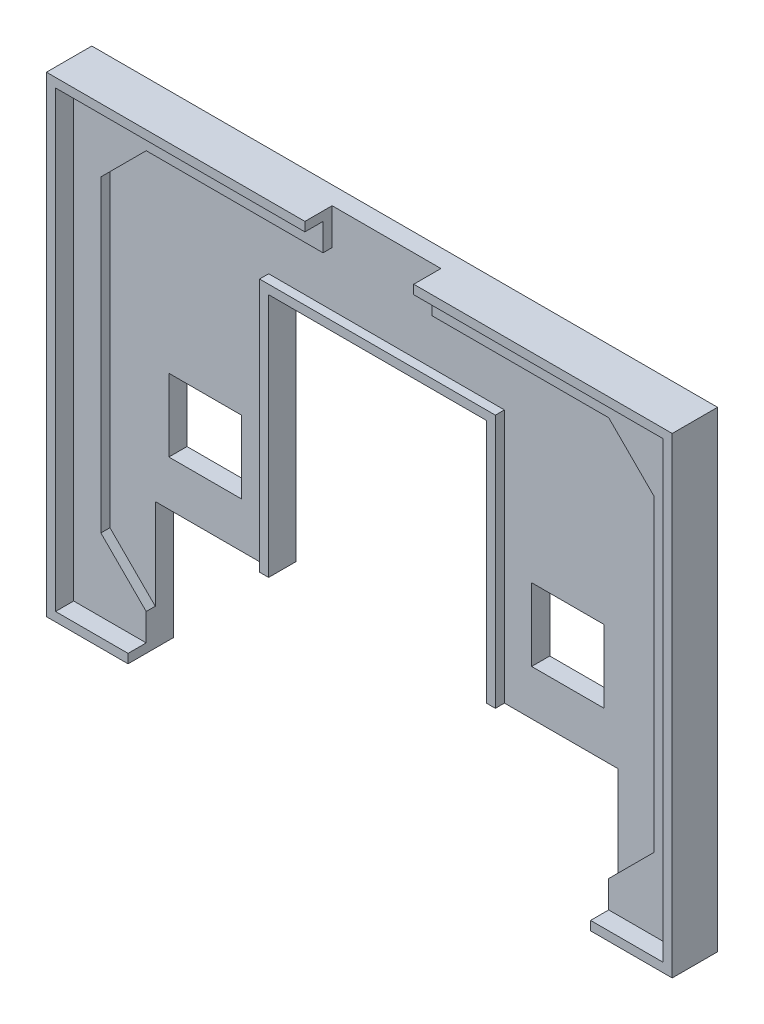
from build123d import *

# Parameters (mm, degrees)
SKICA1_W                    = 67
SKICA1_H                    = 50
P_IDAT_VYSUNUT_M1_DEPTH     = 3
ODEBRAT_VYSUNUT_M1_DEPTH    = 1
SKICA3_W                    = 8
SKICA3_H                    = 8
ODEBRAT_VYSUNUT_M2_DEPTH    = 4
VYSUNOUT_TENKOST_NN_1_DEPTH = 1
VYSUNOUT_TENKOST_NN_2_DEPTH = 5
SKICA6_W                    = 12
SKICA6_H                    = 4
ODEBRAT_VYSUNUT_M3_DEPTH    = 4
ODEBRAT_VYSUNUT_M5_DEPTH    = 1
P_IDAT_START                = -1
P_IDAT_VYSUNUT_M5_DEPTH     = 1
P_IDAT_VYSUNUT_M6_DEPTH     = 1
ODEBRAT_VYSUNUT_M6_DEPTH    = 1
SKICA13_W                   = 1.825387876
SKICA13_H                   = 1.792199005
P_IDAT_VYSUNUT_M7_DEPTH     = 1


with BuildPart() as part:
    # Skica1 → Přidat vysunutím1 (new body)
    with BuildSketch(Plane.XY):
        Rectangle(SKICA1_W, SKICA1_H)
    extrude(amount=P_IDAT_VYSUNUT_M1_DEPTH)

    # Skica2 → Odebrat vysunutím1 (cut)
    with BuildSketch(Plane.XY.offset(3)):
        Polygon((-25.5, -22), (-30.5, -17), (-30.5, 17), (-25.5, 22), (25.5, 22), (30.5, 17), (30.5, -17), (25.5, -22), align=None)
    extrude(amount=-ODEBRAT_VYSUNUT_M1_DEPTH, mode=Mode.SUBTRACT)

    # Skica3 → Odebrat vysunutím2 (cut, through all)
    with BuildSketch(Plane(origin=(0, 0, 0), x_dir=(-1, 0, 0), z_dir=(0, 0, -1))):
        with Locations((20, -3)):
            Rectangle(SKICA3_W, SKICA3_H)
        with Locations((-20, -3)):
            Rectangle(SKICA3_W, SKICA3_H)
        Polygon((25.5, -25), (-25.5, -25), (-25.5, -12), (-12, -12), (-12, 15), (12, 15), (12, -12), (25.5, -12), align=None)
    extrude(amount=-ODEBRAT_VYSUNUT_M2_DEPTH, mode=Mode.SUBTRACT)

    # Skica4 → Vysunout tenkostěnný1 (add)
    with BuildSketch(Plane.XY.offset(2)):
        Polygon((-12, -12), (-12, 15), (12, 15), (12, -12), (13, -12), (13, 16), (-13, 16), (-13, -12), align=None)
    extrude(amount=VYSUNOUT_TENKOST_NN_1_DEPTH)

    # Skica5 → Vysunout tenkostěnný2 (add)
    with BuildSketch(Plane(origin=(0, 0, 0), x_dir=(-1, 0, 0), z_dir=(0, 0, -1))):
        Polygon((-25.5, -25), (-33.5, -25), (-33.5, 25), (33.5, 25), (33.5, -25), (25.5, -25), (25.5, -26), (34.5, -26), (34.5, 26), (-34.5, 26), (-34.5, -26), (-25.5, -26), align=None)
    extrude(amount=-VYSUNOUT_TENKOST_NN_2_DEPTH)

    # Skica6 → Odebrat vysunutím3 (cut, through all)
    with BuildSketch(Plane.XY.offset(2)):
        with Locations((0, 24)):
            Rectangle(SKICA6_W, SKICA6_H)
    extrude(amount=ODEBRAT_VYSUNUT_M3_DEPTH, mode=Mode.SUBTRACT)

    # Skica7 → Odebrat vysunutím5 (cut)
    with BuildSketch(Plane(origin=(0, 0, 0), x_dir=(-1, 0, 0), z_dir=(0, 0, -1))):
        Polygon((-32.44, 14.540476732), (-23.459523268, 23.94), (-14.06, 14.959523268), (-23.040476732, 5.56), align=None)
        Polygon((14.06, 14.959523268), (23.040476732, 5.56), (32.44, 14.540476732), (23.459523268, 23.94), align=None)
    extrude(amount=-ODEBRAT_VYSUNUT_M5_DEPTH, mode=Mode.SUBTRACT)

    # Skica8 → Přidat vysunutím5 (add)
    with BuildSketch(Plane(origin=(0, 0, 0), x_dir=(-1, 0, 0), z_dir=(0, 0, -1)).offset(P_IDAT_START)):
        with BuildLine():
            Line((-29.266904741, 14.966465555), (-25.766904741, 15.0801236))
            add(Edge.make_bspline(
                [(-29.266904741, 14.966465555), (-27.398369795, 11.364860762), (-25.766904741, 15.0801236)],
                knots=[0, 0, 0, 1, 1, 1], degree=2))
        make_face()
        with BuildLine():
            Line((-23.70327201, 17.257603785), (-23.747591798, 20.757603785))
            add(Edge.make_bspline(
                [(-23.70327201, 17.257603785), (-20.063848901, 19.047335046), (-23.747591798, 20.757603785)],
                knots=[0, 0, 0, 1, 1, 1], degree=2))
        make_face()
        with BuildLine():
            Line((29.266904741, 14.966465555), (25.766904741, 15.0801236))
            add(Edge.make_bspline(
                [(29.266904741, 14.966465555), (27.398369795, 11.364860762), (25.766904741, 15.0801236)],
                knots=[0, 0, 0, 1, 1, 1], degree=2))
        make_face()
        with BuildLine():
            Line((23.70327201, 17.257603785), (23.747591798, 20.757603785))
            add(Edge.make_bspline(
                [(23.70327201, 17.257603785), (20.063848901, 19.047335046), (23.747591798, 20.757603785)],
                knots=[0, 0, 0, 1, 1, 1], degree=2))
        make_face()
    extrude(amount=P_IDAT_VYSUNUT_M5_DEPTH)

    # Skica11 → Přidat vysunutím6 (add)
    with BuildSketch(Plane(origin=(0, 0, 0), x_dir=(-1, 0, 0), z_dir=(0, 0, -1)).offset(P_IDAT_START)):
        Polygon((-25.724541131, 9.230843392), (-24.69196981, 9.842232358), (-24.987531509, 11.719102967), (-22.99084361, 11.83415701), (-22.744580902, 14.120935241), (-20.448389818, 14.25324739), (-20.234248333, 16.2417502), (-18.334248333, 16.35123285), (-17.798682715, 17.425090135), (-17.654074665, 17.286928954), (-17.037308405, 14.35101353), (-18.237308405, 14.35101353), (-18.595837474, 12.383411714), (-20.461373652, 12.023169065), (-20.664808063, 10.134091396), (-22.628530356, 9.754888608), (-22.628530356, 8.554888608), (-25.57993308, 9.092682212), align=None)
        Polygon((22.628530356, 8.554888608), (25.57993308, 9.092682212), (25.724541131, 9.230843392), (24.69196981, 9.842232358), (24.987531509, 11.719102967), (22.99084361, 11.83415701), (22.744580902, 14.120935241), (20.448389818, 14.25324739), (20.234248333, 16.2417502), (18.334248333, 16.35123285), (17.798682715, 17.425090135), (17.654074665, 17.286928954), (17.037308405, 14.35101353), (18.237308405, 14.35101353), (18.595837474, 12.383411714), (20.461373652, 12.023169065), (20.664808063, 10.134091396), (22.628530356, 9.754888608), align=None)
    extrude(amount=P_IDAT_VYSUNUT_M6_DEPTH)

    # Skica12 → Odebrat vysunutím6 (cut)
    with BuildSketch(Plane(origin=(0, 0, 0), x_dir=(-1, 0, 0), z_dir=(0, 0, -1))):
        Polygon((-10.16, 23.3), (-6.369480049, 23.3), (-6.369480049, 22.56693444), (-5.70000808, 22.56693444), (-5.70000808, 20.774735435), (-6.347191054, 20.774735435), (-6.347191054, 20.077769155), (-6.944590723, 20.077769155), (-6.944590723, 19.546747227), (-6.347191054, 19.546747227), (-6.347191054, 18.733619901), (-5.70000808, 18.733619901), (-5.70000808, 17.804331528), (-7.143723945, 17.804331528), (-7.143723945, 18.501297807), (-7.774312484, 18.501297807), (-7.774312484, 19.140183564), (-8.253595527, 19.140183564), (-8.253595527, 20.077769155), (-8.769978599, 20.077769155), (-8.769978599, 17.804331528), (-10.16, 17.804331528), align=None)
        Polygon((-4.936617449, 23.3), (-3.432005952, 23.3), (-3.432005952, 18.733619901), (-1.815348918, 18.733619901), (-1.815348918, 23.3), (-0.352474449, 23.3), (-0.352474449, 18.501297807), (-1.072767186, 18.501297807), (-1.072767186, 17.804331528), (-4.258061738, 17.804331528), (-4.258061738, 18.501297807), (-4.936617449, 18.501297807), align=None)
        Polygon((4.306009733, 22.56693444), (4.967857854, 22.56693444), (4.967857854, 21.583119882), (3.37998692, 21.583119882), (3.37998692, 22.255759653), (1.9023848, 22.255759653), (1.9023848, 21.01680995), (4.251110557, 21.01680995), (4.251110557, 20.304001629), (4.967857854, 20.304001629), (4.967857854, 18.501297807), (4.251110557, 18.501297807), (4.251110557, 17.804331528), (1.031261162, 17.804331528), (1.031261162, 18.501297807), (0.42478268, 18.501297807), (0.42478268, 19.546747227), (1.9023848, 19.546747227), (1.9023848, 18.820740686), (3.468201971, 18.820740686), (3.468201971, 20.077769155), (1.031261162, 20.077769155), (1.031261162, 20.774735435), (0.42478268, 20.774735435), (0.42478268, 22.56693444), (1.031261162, 22.56693444), (1.031261162, 23.3), (4.306009733, 23.3), align=None)
        Polygon((5.672754202, 23.3), (7.173807496, 23.3), (7.173807496, 21.079366958), (8.764209199, 21.079366958), (8.764209199, 23.3), (10.1580444, 23.3), (10.1580444, 17.804331528), (8.764209199, 17.804331528), (8.764209199, 20.077769155), (7.173807496, 20.077769155), (7.173807496, 17.804331528), (5.672754202, 17.804331528), align=None)
    extrude(amount=-ODEBRAT_VYSUNUT_M6_DEPTH, mode=Mode.SUBTRACT)

    # Skica13 → Přidat vysunutím7 (add)
    with BuildSketch(Plane(origin=(0, 0, 0), x_dir=(-1, 0, 0), z_dir=(0, 0, -1)).offset(P_IDAT_START)):
        with Locations((-7.857284661, 21.670834938)):
            Rectangle(SKICA13_W, SKICA13_H)
    extrude(amount=P_IDAT_VYSUNUT_M7_DEPTH)


solid = part.part
